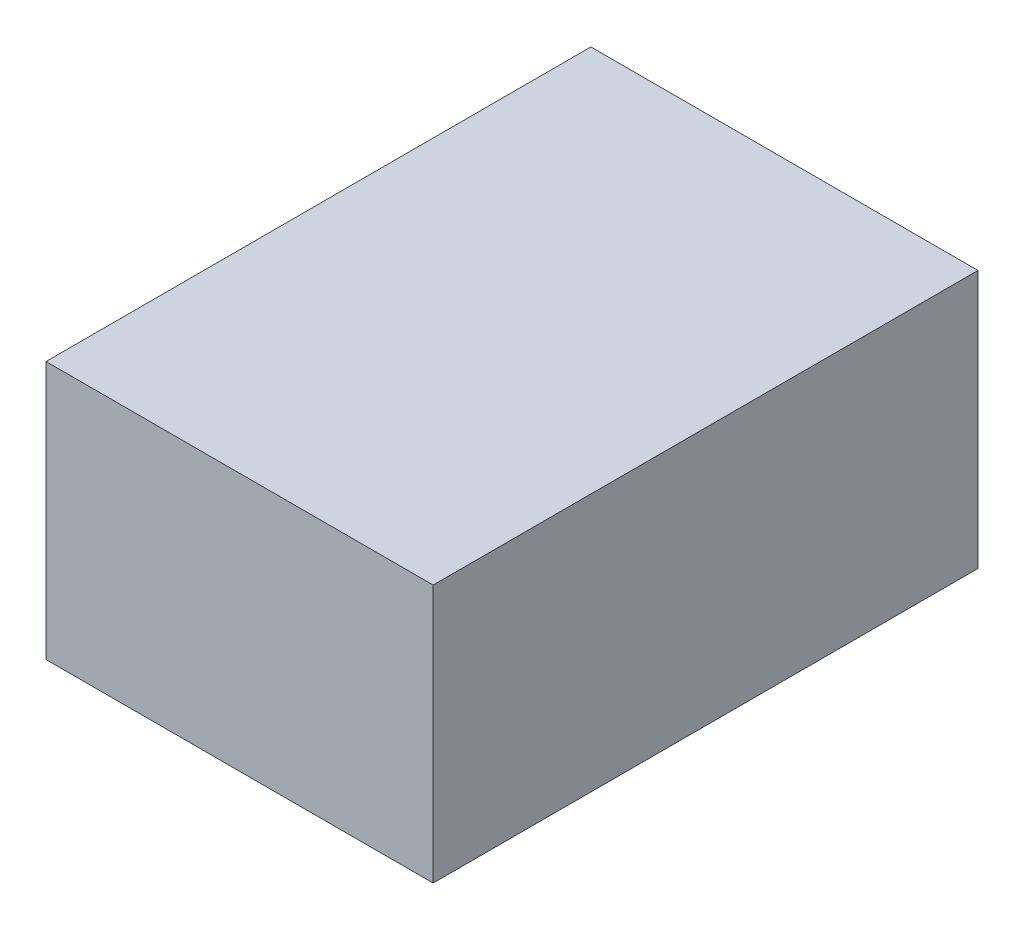
from build123d import *

# Parameters (mm, degrees)
SKETCH1_W           = 27
SKETCH1_H           = 38
BOSS_EXTRUDE1_DEPTH = 18


with BuildPart() as part:
    # Sketch1 → Boss-Extrude1 (new body)
    with BuildSketch(Plane(origin=(0, 0, 0), x_dir=(1, 0, 0), z_dir=(0, 1, 0))):
        with Locations((13.5, 19)):
            Rectangle(SKETCH1_W, SKETCH1_H)
    extrude(amount=BOSS_EXTRUDE1_DEPTH)


solid = part.part
